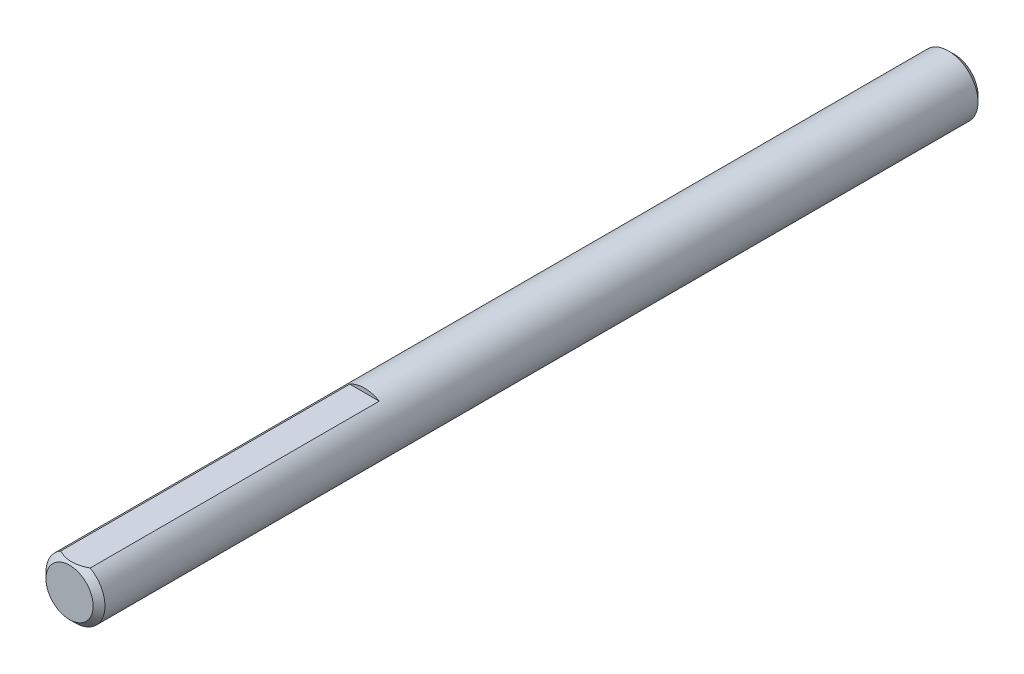
from build123d import *

# Parameters (mm, degrees)
SKETCH1_R      = 2.54
EXTRUDE1_DEPTH = 38.1
CHAMFER1_SIZE  = 0.508
EXTRUDE7_DEPTH = 26.4


with BuildPart() as part:
    # Sketch1 → Extrude1 (new body, symmetric)
    with BuildSketch(Plane.XY):
        Circle(SKETCH1_R)
    extrude(amount=EXTRUDE1_DEPTH, both=True)

    # Chamfer1
    chamfer1_edges = [part.edges().sort_by_distance(p)[0] for p in [
        (-2.54, 0, -38.1),
        (-2.54, 0, 38.1),
    ]]
    chamfer(chamfer1_edges, length=CHAMFER1_SIZE)

    # Sketch13 → Extrude7 (cut, through all)
    with BuildSketch(Plane.XY.offset(12.7)):
        with BuildLine():
            Line((-1.27, 2.199704526), (1.27, 2.199704526))
            ThreePointArc((1.27, 2.199704526), (0, 2.54), (-1.27, 2.199704526))
        make_face()
    extrude(amount=EXTRUDE7_DEPTH, mode=Mode.SUBTRACT)


solid = part.part
